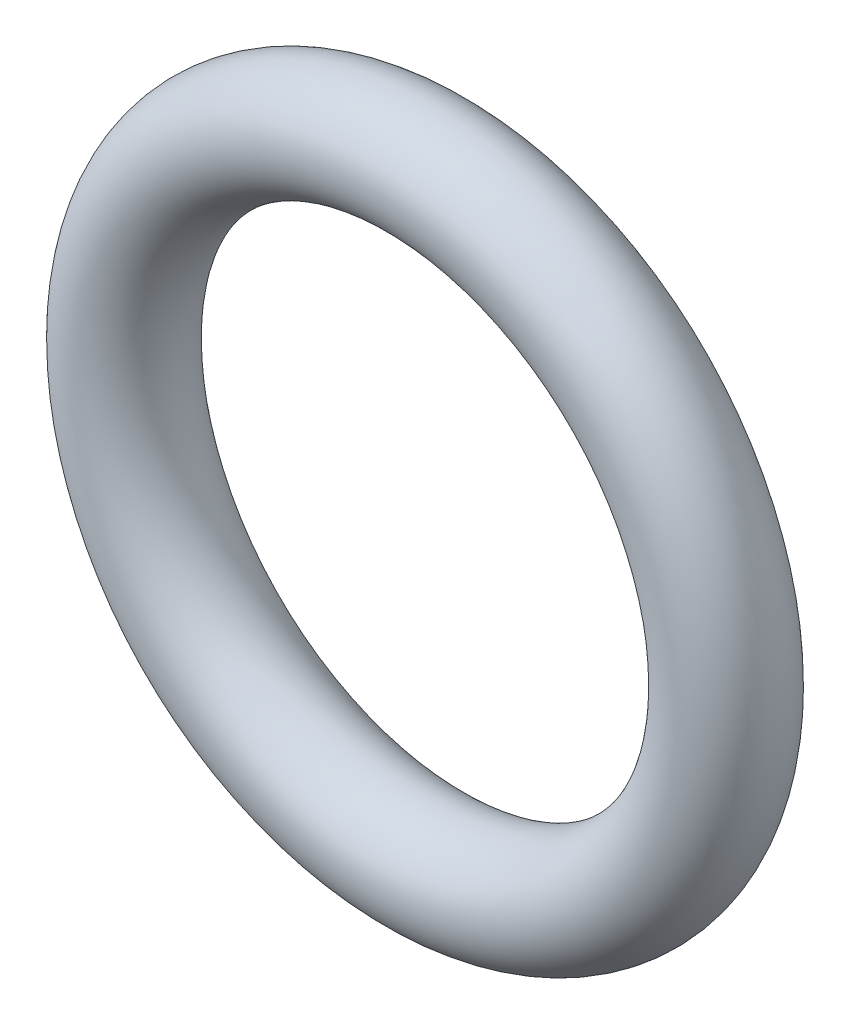
from build123d import *

# Parameters (mm, degrees)
SKETCH2_R = 1.2


with BuildPart() as part:
    # Sweep1: sweep along a path in Sketch1
    with BuildLine(Plane.XY) as sweep1_path:
        CenterArc((0, 0), 5.4, 0, 360)
    # Sketch2 → Sweep1 (sweep)
    with BuildSketch(Plane(origin=(0, 0, 0), x_dir=(1, 0, 0), z_dir=(0, 1, 0))):
        with Locations((-6.6, 0)):
            Circle(SKETCH2_R)
    sweep(path=sweep1_path.line)


solid = part.part
